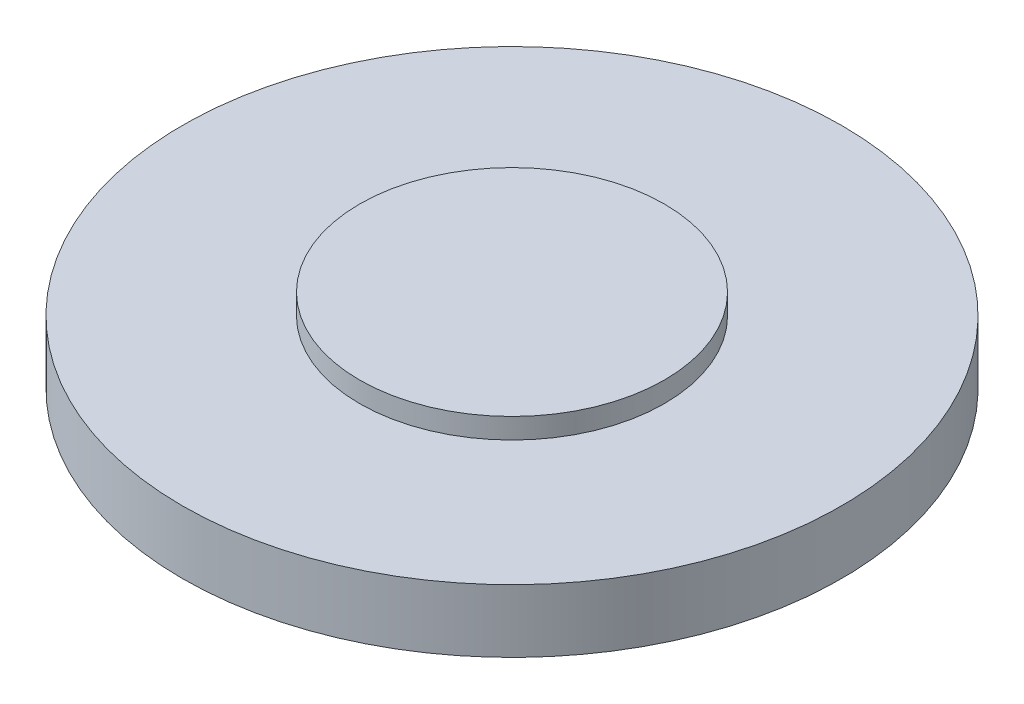
from build123d import *

# Parameters (mm, degrees)
SKETCH2_R           = 19.35
BOSS_EXTRUDE1_DEPTH = 3.7
SKETCH3_R           = 8.95
BOSS_EXTRUDE2_DEPTH = 1.2
SKETCH4_R           = 18.55
CUT_EXTRUDE1_DEPTH  = 1.5


with BuildPart() as part:
    # Sketch2 → Boss-Extrude1 (new body)
    with BuildSketch(Plane(origin=(0, 0, 0), x_dir=(1, 0, 0), z_dir=(0, 1, 0))):
        with Locations(Location((0, 0, 0), (0, 0, 270))):  # turned: the seam where the file's is
            Circle(SKETCH2_R)
    extrude(amount=BOSS_EXTRUDE1_DEPTH)

    # Sketch3 → Boss-Extrude2 (add)
    with BuildSketch(Plane(origin=(0, 3.7, 0), x_dir=(1, 0, 0), z_dir=(0, 1, 0))):
        with Locations(Location((0, 0, 0), (0, 0, 270))):  # turned: the seam where the file's is
            Circle(SKETCH3_R)
    extrude(amount=BOSS_EXTRUDE2_DEPTH)

    # Sketch4 → Cut-Extrude1 (cut)
    with BuildSketch(Plane.XZ):
        with Locations(Location((0, 0, 0), (0, 0, 270))):  # turned: the seam where the file's is
            Circle(SKETCH4_R)
    extrude(amount=-CUT_EXTRUDE1_DEPTH, mode=Mode.SUBTRACT)


solid = part.part
